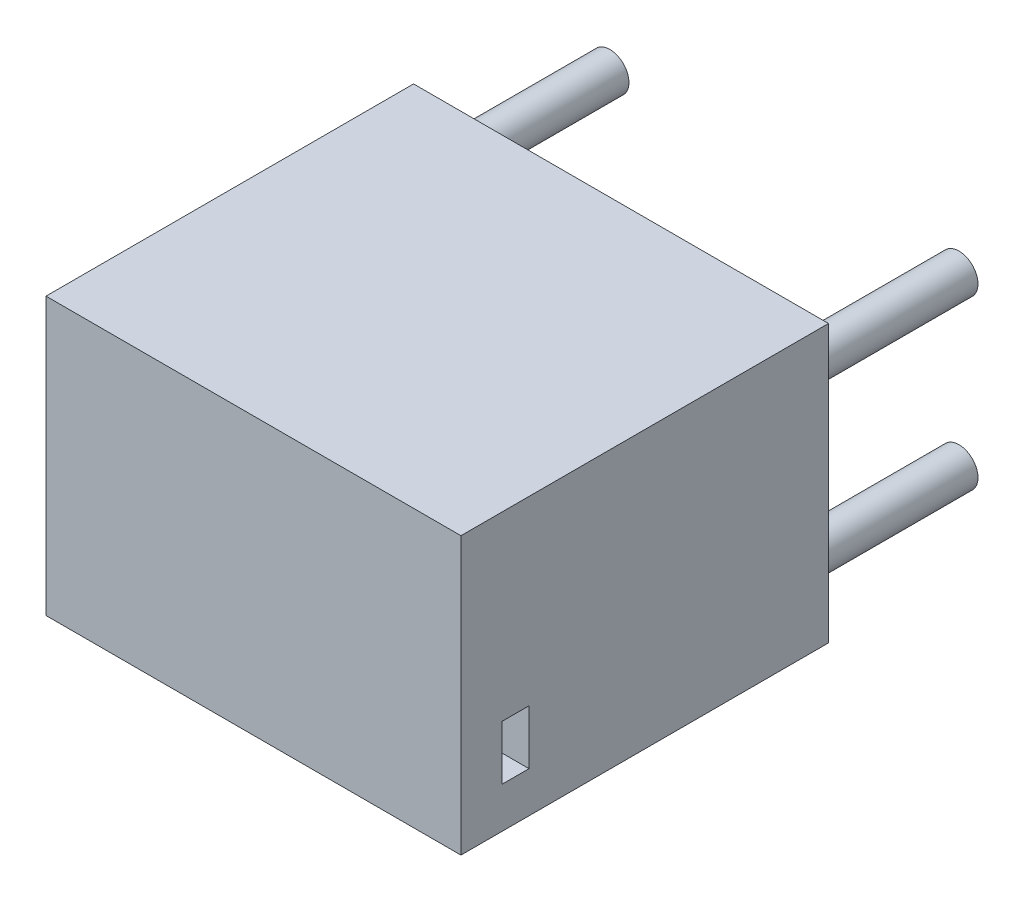
from build123d import *

# Parameters (mm, degrees)
SKETCH1_W           = 152.4
SKETCH1_H           = 101.6
BOSS_EXTRUDE1_DEPTH = 135
SKETCH2_W           = 104
SKETCH2_H           = 78
CUT_EXTRUDE1_DEPTH  = 6
SKETCH4_R           = 7
BOSS_EXTRUDE3_DEPTH = 60
SKETCH5_R           = 4.5
CUT_EXTRUDE3_DEPTH  = 80
SKETCH12_W          = 100
SKETCH12_H          = 75.5
CUT_EXTRUDE7_DEPTH  = 120
SKETCH13_W          = 60
SKETCH13_H          = 42
CUT_EXTRUDE8_DEPTH  = 2
SKETCH24_R          = 2.5
CUT_EXTRUDE9_DEPTH  = 15
SKETCH26_W          = 10
SKETCH26_H          = 20
CUT_EXTRUDE10_DEPTH = 27.2


with BuildPart() as part:
    # Sketch1 → Boss-Extrude1 (new body)
    with BuildSketch(Plane.XY):
        Rectangle(SKETCH1_W, SKETCH1_H)
    extrude(amount=BOSS_EXTRUDE1_DEPTH)

    # Sketch2 → Cut-Extrude1 (cut)
    with BuildSketch(Plane(origin=(0, 0, 0), x_dir=(-1, 0, 0), z_dir=(0, 0, -1))):
        Rectangle(SKETCH2_W, SKETCH2_H)
    extrude(amount=-CUT_EXTRUDE1_DEPTH, mode=Mode.SUBTRACT)

    # Sketch4 → Boss-Extrude3 (add)
    with BuildSketch(Plane(origin=(0, 0, 0), x_dir=(-1, 0, 0), z_dir=(0, 0, -1))):
        with Locations((-64.1, -30.8)):
            Circle(SKETCH4_R)
        with Locations((-64.1, 30.8)):
            Circle(SKETCH4_R)
        with Locations((64.1, 30.8)):
            Circle(SKETCH4_R)
        with Locations((64.1, -30.8)):
            Circle(SKETCH4_R)
    extrude(amount=BOSS_EXTRUDE3_DEPTH)

    # Sketch5 → Cut-Extrude3 (cut)
    with BuildSketch(Plane(origin=(0, 0, -60), x_dir=(-1, 0, 0), z_dir=(0, 0, -1))):
        with Locations((-64.1, 30.8)):
            Circle(SKETCH5_R)
        with Locations((64.1, 30.8)):
            Circle(SKETCH5_R)
        with Locations((64.1, -30.8)):
            Circle(SKETCH5_R)
        with Locations((-64.1, -30.8)):
            Circle(SKETCH5_R)
    extrude(amount=-CUT_EXTRUDE3_DEPTH, mode=Mode.SUBTRACT)

    # Sketch12 → Cut-Extrude7 (cut)
    with BuildSketch(Plane(origin=(0, 0, 6), x_dir=(-1, 0, 0), z_dir=(0, 0, -1))):
        Rectangle(SKETCH12_W, SKETCH12_H)
    extrude(amount=-CUT_EXTRUDE7_DEPTH, mode=Mode.SUBTRACT)

    # Sketch13 → Cut-Extrude8 (cut)
    with BuildSketch(Plane(origin=(0, 0, 126), x_dir=(-1, 0, 0), z_dir=(0, 0, -1))):
        with Locations((0, 4.75)):
            Rectangle(SKETCH13_W, SKETCH13_H)
    extrude(amount=-CUT_EXTRUDE8_DEPTH, mode=Mode.SUBTRACT)

    # Sketch24 → Cut-Extrude9 (cut)
    with BuildSketch(Plane.ZY.offset(-50)):
        with Locations((12.5, 30.8)):
            Circle(SKETCH24_R)
        with Locations((12.5, -30.8)):
            Circle(SKETCH24_R)
    cut_extrude9 = extrude(amount=-CUT_EXTRUDE9_DEPTH, mode=Mode.SUBTRACT)

    # Mirror2: Cut-Extrude9 across plane
    add(cut_extrude9.mirror(Plane(origin=(0, 0, 0), x_dir=(0, 0, 1), z_dir=(1, 0, 0))), mode=Mode.SUBTRACT)

    # Sketch26 → Cut-Extrude10 (cut, through all)
    with BuildSketch(Plane.ZY.offset(-50)):
        with Locations((115, -25.8)):
            Rectangle(SKETCH26_W, SKETCH26_H)
    extrude(amount=-CUT_EXTRUDE10_DEPTH, mode=Mode.SUBTRACT)


solid = part.part
